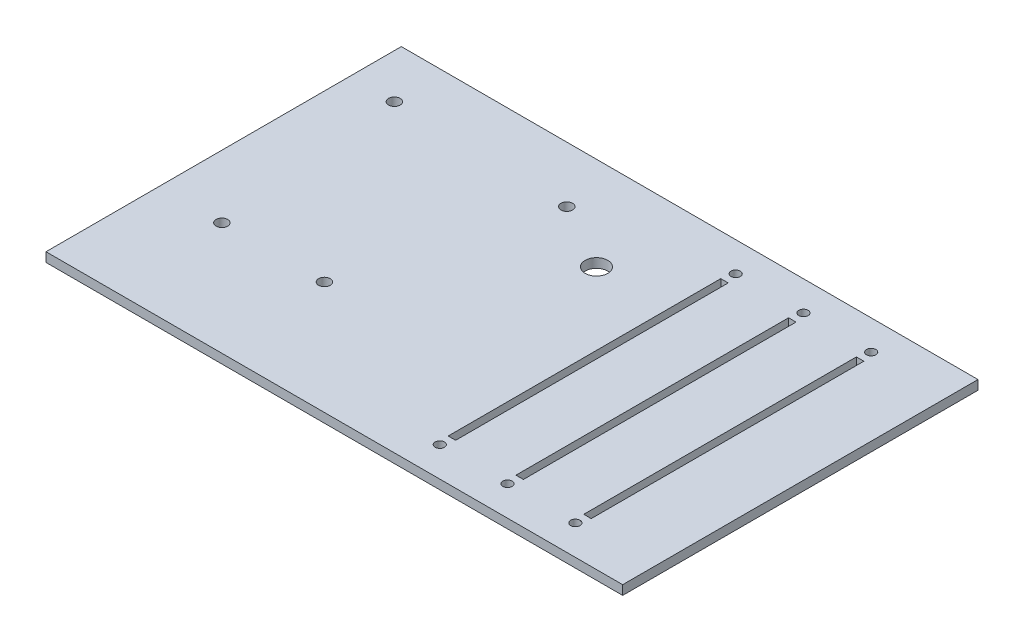
from build123d import *

# Parameters (mm, degrees)
SKETCH1_W           = 157.1625
SKETCH1_H           = 96.8375
SKETCH1_R           = 1.5875
SKETCH1_R_2         = 1.27
SKETCH1_R_3         = 3.0861
SKETCH1_W_2         = 2.032
SKETCH1_H_2         = 74.295
BOSS_EXTRUDE1_DEPTH = 2.54


with BuildPart() as part:
    # Sketch1 → Boss-Extrude1 (new body)
    with BuildSketch(Plane(origin=(0, 0, 0), x_dir=(1, 0, 0), z_dir=(0, 1, 0))):
        Rectangle(SKETCH1_W, SKETCH1_H)
        with Locations((-66.51625, 34.44875)):
            Circle(SKETCH1_R, mode=Mode.SUBTRACT)
        with Locations((-61.43625, -17.62125)):
            Circle(SKETCH1_R, mode=Mode.SUBTRACT)
        with Locations((-33.49625, -17.62125)):
            Circle(SKETCH1_R, mode=Mode.SUBTRACT)
        with Locations((-18.25625, 33.17875)):
            Circle(SKETCH1_R, mode=Mode.SUBTRACT)
        with Locations((57.56275, 40.32885)):
            Circle(SKETCH1_R_2, mode=Mode.SUBTRACT)
        with Locations((39.08425, 40.35425)):
            Circle(SKETCH1_R_2, mode=Mode.SUBTRACT)
        with Locations((20.60575, 40.35425)):
            Circle(SKETCH1_R_2, mode=Mode.SUBTRACT)
        with Locations((57.56275, -40.29075)):
            Circle(SKETCH1_R_2, mode=Mode.SUBTRACT)
        with Locations((39.08425, -40.29075)):
            Circle(SKETCH1_R_2, mode=Mode.SUBTRACT)
        with Locations((20.60575, -40.29075)):
            Circle(SKETCH1_R_2, mode=Mode.SUBTRACT)
        with Locations((0, 23.01875)):
            Circle(SKETCH1_R_3, mode=Mode.SUBTRACT)
        with Locations((20.73275, 0.03175)):
            Rectangle(SKETCH1_W_2, SKETCH1_H_2, mode=Mode.SUBTRACT)
        with Locations((39.21125, 0.03175)):
            Rectangle(SKETCH1_W_2, SKETCH1_H_2, mode=Mode.SUBTRACT)
        with Locations((57.68975, 0.03175)):
            Rectangle(SKETCH1_W_2, SKETCH1_H_2, mode=Mode.SUBTRACT)
    extrude(amount=BOSS_EXTRUDE1_DEPTH)


solid = part.part
